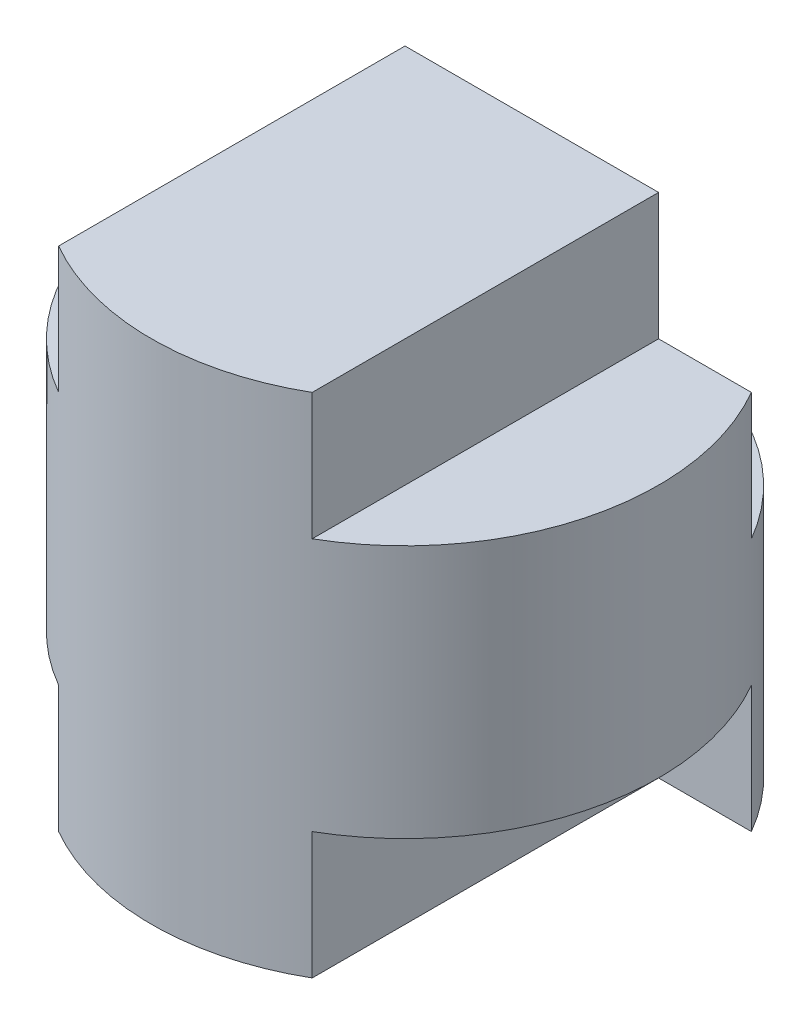
from build123d import *

# Parameters (mm, degrees)
SKETCH1_R               = 2
BOSS_EXTRUDE1_DEPTH     = 4
SKETCH2_W               = 1
SKETCH2_H               = 1
CUT_EXTRUDE1_DEPTH      = 4
CUT_EXTRUDE1_DEPTH_BACK = 1
CUT_EXTRUDE2_DEPTH      = 2


with BuildPart() as part:
    # Sketch1 → Boss-Extrude1 (new body)
    with BuildSketch(Plane(origin=(0, 0, 0), x_dir=(1, 0, 0), z_dir=(0, 1, 0))):
        Circle(SKETCH1_R)
    extrude(amount=BOSS_EXTRUDE1_DEPTH)

    # Sketch2 → Cut-Extrude1 (cut, two sides)
    with BuildSketch(Plane.XY) as cut_extrude1_sk:
        with Locations((-1.5, 0.5)):
            Rectangle(SKETCH2_W, SKETCH2_H)
        with Locations((1.5, 0.5)):
            Rectangle(SKETCH2_W, SKETCH2_H)
        with Locations((1.5, 3.5)):
            Rectangle(SKETCH2_W, SKETCH2_H)
        with Locations((-1.5, 3.5)):
            Rectangle(SKETCH2_W, SKETCH2_H)
    extrude(amount=CUT_EXTRUDE1_DEPTH, mode=Mode.SUBTRACT)
    extrude(cut_extrude1_sk.sketch, amount=-CUT_EXTRUDE1_DEPTH_BACK, mode=Mode.SUBTRACT)

    # Sketch3 → Cut-Extrude2 (cut)
    with BuildSketch(Plane(origin=(0, 4, 0), x_dir=(1, 0, 0), z_dir=(0, 1, 0))):
        with BuildLine():
            Line((-1.732050808, 1), (1.732050808, 1))
            ThreePointArc((1.732050808, 1), (0, 2), (-1.732050808, 1))
        make_face()
    extrude(amount=-CUT_EXTRUDE2_DEPTH, mode=Mode.SUBTRACT)


solid = part.part
